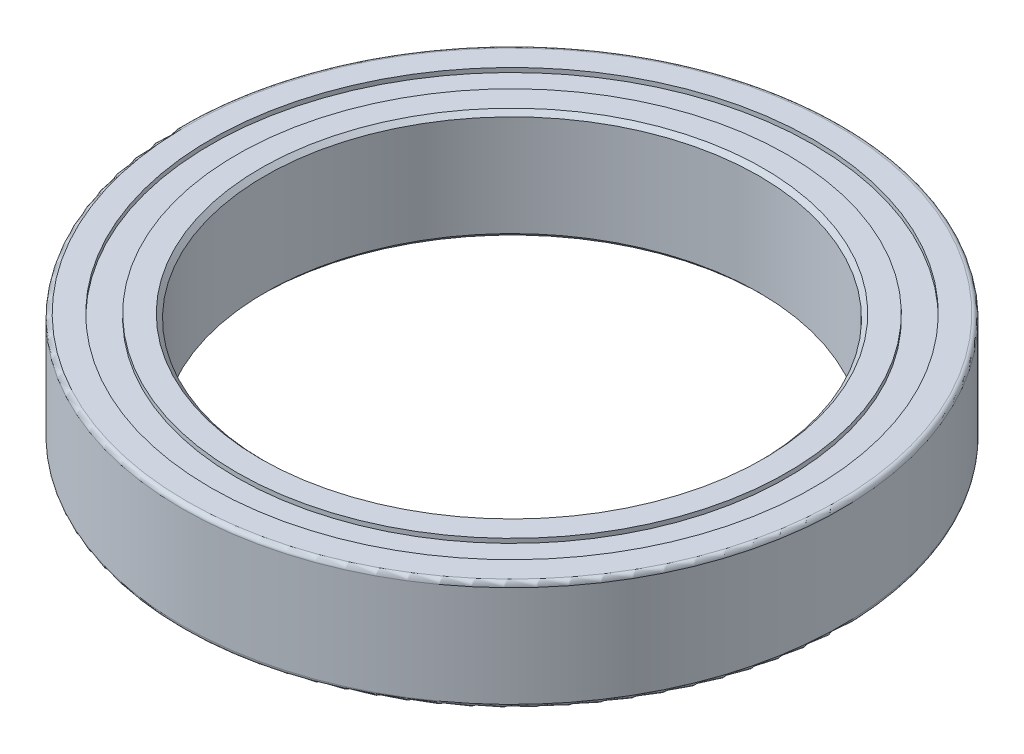
from build123d import *

# Parameters (mm, degrees)
SKETCH1_R             = 9.525
SKETCH1_R_2           = 8.7122
BOSS_EXTRUDE1_DEPTH   = 1.5875
SKETCH1_R_3           = 7.95655
SKETCH1_R_4           = 7.14375
BOSS_EXTRUDE1_2_DEPTH = 1.5875
FILLET1_R             = 0.127
CHAMFER1_SIZE         = 0.127
SKETCH2_R             = 8.7122
SKETCH2_R_2           = 7.95655
BOSS_EXTRUDE2_DEPTH   = 1.4605


with BuildPart() as part:
    # Sketch1 → Boss-Extrude1 (new body, symmetric)
    with BuildSketch(Plane(origin=(0, 0, 0), x_dir=(1, 0, 0), z_dir=(0, 1, 0))):
        Circle(SKETCH1_R)
        Circle(SKETCH1_R_2, mode=Mode.SUBTRACT)
    extrude(amount=BOSS_EXTRUDE1_DEPTH, both=True)

    # Fillet1
    fillet1_edges = [part.edges().sort_by_distance(p)[0] for p in [
        (-9.525, -1.5875, 0),
        (-9.525, 1.5875, 0),
    ]]
    fillet(fillet1_edges, radius=FILLET1_R)



with BuildPart() as body_2:
    # Sketch1 → Boss-Extrude1 2 (new body, symmetric)
    with BuildSketch(Plane(origin=(0, 0, 0), x_dir=(1, 0, 0), z_dir=(0, 1, 0))):
        Circle(SKETCH1_R_3)
        Circle(SKETCH1_R_4, mode=Mode.SUBTRACT)
    extrude(amount=BOSS_EXTRUDE1_2_DEPTH, both=True)

    # Chamfer1
    chamfer1_edges = [body_2.edges().sort_by_distance(p)[0] for p in [
        (-7.14375, -1.5875, 0),
        (-7.14375, 1.5875, 0),
    ]]
    chamfer(chamfer1_edges, length=CHAMFER1_SIZE)


with BuildPart() as part_1:
    add(part.part)

    add(body_2.part)  # Boss-Extrude2 merges body 2
    # Sketch2 → Boss-Extrude2 (add, symmetric)
    with BuildSketch(Plane(origin=(0, 0, 0), x_dir=(1, 0, 0), z_dir=(0, 1, 0))):
        Circle(SKETCH2_R)
        Circle(SKETCH2_R_2, mode=Mode.SUBTRACT)
    extrude(amount=BOSS_EXTRUDE2_DEPTH, both=True)


solid = part_1.part
